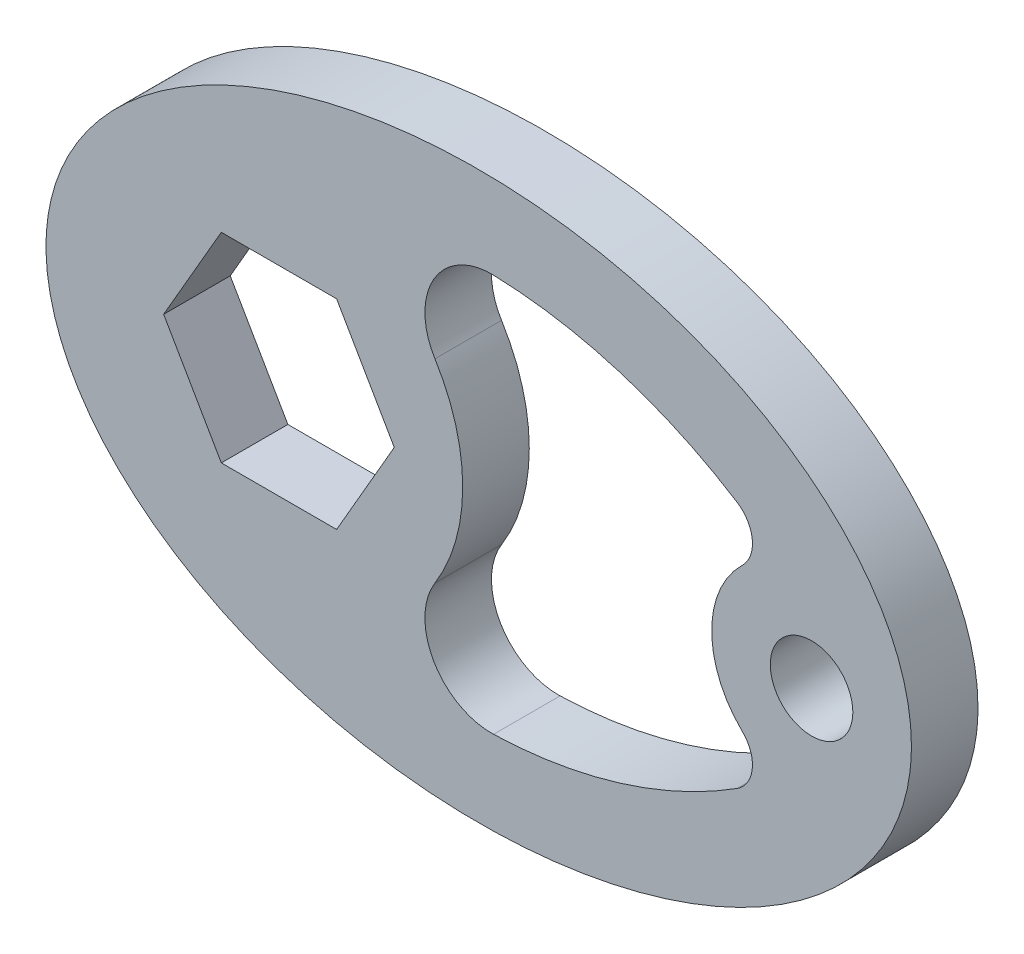
from build123d import *

# Parameters (mm, degrees)
SKETCH1_RX          = 82.55
SKETCH1_RY          = 53.975
SKETCH1_R           = 7.874
BOSS_EXTRUDE1_DEPTH = 12.7


with BuildPart() as part:
    # Sketch1 → Boss-Extrude1 (new body)
    with BuildSketch(Plane.XY):
        with Locations((0, 0)):
            Ellipse(SKETCH1_RX, SKETCH1_RY)
        with Locations((63.5, 0)):
            Circle(SKETCH1_R, mode=Mode.SUBTRACT)
        Polygon((-16.102954744, 0), (-27.101477372, 19.05), (-49.098522628, 19.05), (-60.097045256, 0), (-49.098522628, -19.05), (-27.101477372, -19.05), align=None, mode=Mode.SUBTRACT)
        with BuildLine():
            ThreePointArc((50.282192855, 13.718311641), (44.45, 0), (50.282192855, -13.718311641))
            ThreePointArc((50.282192855, -13.718311641), (52.194156422, -18.928772289), (49.279540311, -23.652067514))
            ThreePointArc((49.279540311, -23.652067514), (27.015068096, -33.914821935), (2.830078432, -37.92943602))
            ThreePointArc((2.830078432, -37.92943602), (-8.566993644, -31.572176432), (-8.342514151, -18.523896457))
            ThreePointArc((-8.342514151, -18.523896457), (-3.048, 0), (-8.342514151, 18.523896457))
            ThreePointArc((-8.342514151, 18.523896457), (-8.566993644, 31.572176432), (2.830078432, 37.92943602))
            ThreePointArc((2.830078432, 37.92943602), (27.015068096, 33.914821935), (49.279540311, 23.652067514))
            ThreePointArc((49.279540311, 23.652067514), (52.194156422, 18.928772289), (50.282192855, 13.718311641))
        make_face(mode=Mode.SUBTRACT)
    extrude(amount=BOSS_EXTRUDE1_DEPTH)


solid = part.part
